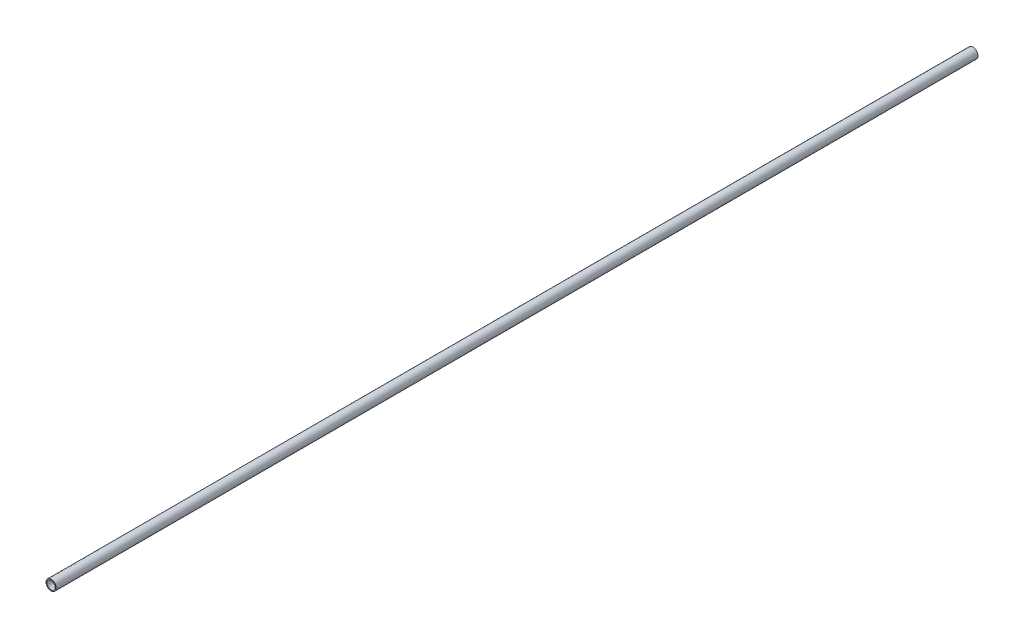
from build123d import *

# Parameters (mm, degrees)
SKETCH1_R           = 5.5
SKETCH1_R_2         = 4.5
BOSS_EXTRUDE1_DEPTH = 1000


with BuildPart() as part:
    # Sketch1 → Boss-Extrude1 (new body)
    with BuildSketch(Plane.XY):
        Circle(SKETCH1_R)
        Circle(SKETCH1_R_2, mode=Mode.SUBTRACT)
    extrude(amount=BOSS_EXTRUDE1_DEPTH)


solid = part.part
